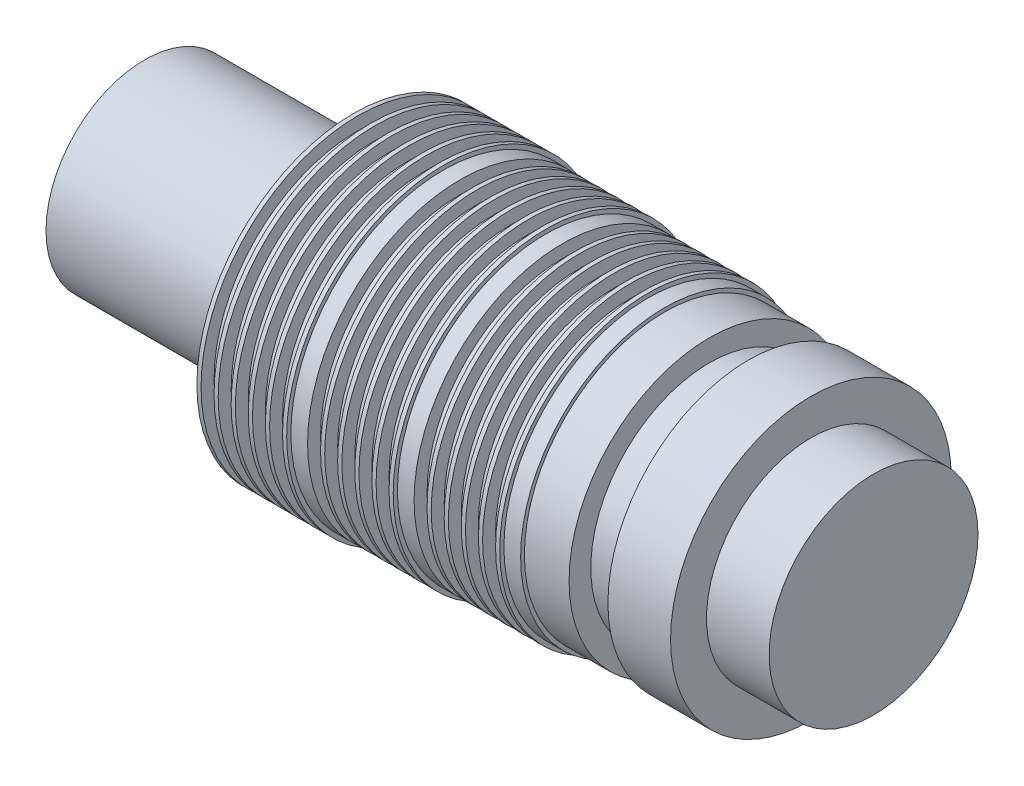
from build123d import *

# Parameters (mm, degrees)
SKETCH3_R           = 17.357767681
CUT_EXTRUDE1_DEPTH  = 114.5794
SKETCH4_R           = 6.35
BOSS_EXTRUDE1_DEPTH = 12.7
SKETCH5_R           = 8.5344
SKETCH5_R_2         = 6.35
BOSS_EXTRUDE2_DEPTH = 8.89
CUT_EXTRUDE2_START  = -3.81
SKETCH6_R           = 8.5344
SKETCH6_R_2         = 7.2136
CUT_EXTRUDE2_DEPTH  = 2.3622


with BuildPart() as part:
    # Sketch1 → Revolve1 (revolve)
    with BuildSketch(Plane.XY):
        Polygon((12.954, 9.525), (12.954, 8.7376), (13.7414, 8.7376), (13.7414, 9.525), (13.9954, 9.525), (13.9954, 8.7376), (14.7828, 8.7376), (14.7828, 9.525), (15.0368, 9.525), (15.0368, 8.7376), (15.8242, 8.7376), (15.8242, 9.525), (16.0782, 9.525), (16.0782, 8.7376), (16.8656, 8.7376), (16.8656, 9.525), (17.1196, 9.525), (17.1196, 8.7376), (17.907, 8.7376), (17.907, 9.525), (18.161, 9.525), (18.161, 9.271), (19.177, 9.271), (19.177, 8.4836), (19.9644, 8.4836), (19.9644, 9.271), (20.2184, 9.271), (20.2184, 8.4836), (21.0058, 8.4836), (21.0058, 9.271), (21.2598, 9.271), (21.2598, 8.4836), (22.0472, 8.4836), (22.0472, 9.271), (22.3012, 9.271), (22.3012, 8.4836), (23.0886, 8.4836), (23.0886, 9.271), (23.3426, 9.271), (23.3426, 8.4836), (24.13, 8.4836), (24.13, 9.271), (24.384, 9.271), (24.384, 9.017), (25.4, 9.017), (25.4, 8.2296), (26.1874, 8.2296), (26.1874, 9.017), (26.4414, 9.017), (26.4414, 8.2296), (27.2288, 8.2296), (27.2288, 9.017), (27.4828, 9.017), (27.4828, 8.2296), (28.2702, 8.2296), (28.2702, 9.017), (28.5242, 9.017), (28.5242, 8.2296), (29.3116, 8.2296), (29.3116, 9.017), (29.5656, 9.017), (29.5656, 8.2296), (30.353, 8.2296), (30.353, 9.017), (30.607, 9.017), (30.607, 8.763), (31.623, 8.763), (31.623, 7.9756), (32.4104, 7.9756), (32.4104, 8.763), (32.6644, 8.763), (32.6644, 7.9756), (33.4518, 7.9756), (33.4518, 8.763), (33.7058, 8.763), (33.7058, 7.9756), (34.4932, 7.9756), (34.4932, 8.763), (34.7472, 8.763), (34.7472, 7.9756), (35.5346, 7.9756), (35.5346, 8.763), (35.7886, 8.763), (35.7886, 7.9756), (36.576, 7.9756), (36.576, 8.763), (36.83, 8.763), (36.83, 8.509), (37.846, 8.509), (37.846, 7.7216), (38.6334, 7.7216), (38.6334, 8.509), (38.8874, 8.509), (38.8874, 7.7216), (39.6748, 7.7216), (39.6748, 8.509), (39.9288, 8.509), (39.9288, 7.7216), (40.7162, 7.7216), (40.7162, 8.509), (40.9702, 8.509), (40.9702, 7.7216), (41.7576, 7.7216), (41.7576, 8.509), (42.0116, 8.509), (42.0116, 7.7216), (42.799, 7.7216), (42.799, 8.509), (43.053, 8.509), (43.053, 8.255), (44.069, 8.255), (44.069, 7.4676), (44.8564, 7.4676), (44.8564, 8.255), (45.1104, 8.255), (45.1104, 7.4676), (45.8978, 7.4676), (45.8978, 8.255), (46.1518, 8.255), (46.1518, 7.4676), (46.9392, 7.4676), (46.9392, 8.255), (47.1932, 8.255), (47.1932, 7.4676), (47.9806, 7.4676), (47.9806, 8.255), (48.2346, 8.255), (48.2346, 7.4676), (49.022, 7.4676), (49.022, 8.255), (49.276, 8.255), (49.276, 5.999988), (74.676, 5.999988), (74.676, 0), (61.976, 0), (0, 0), (0, 5.999988), (12.7, 5.999988), (12.7, 9.525), align=None)
    revolve(axis=Axis((0, 0, 0), (1, 0, 0)))

    # Sketch3 → Cut-Extrude1 (cut)
    with BuildSketch(Plane(origin=(31.623, 0, 0), x_dir=(0, 0, -1), z_dir=(1, 0, 0))):
        Circle(SKETCH3_R)
    extrude(amount=CUT_EXTRUDE1_DEPTH, mode=Mode.SUBTRACT)

    # Sketch4 → Boss-Extrude1 (add)
    with BuildSketch(Plane(origin=(31.623, 0, 0), x_dir=(0, 0, -1), z_dir=(1, 0, 0))):
        Circle(SKETCH4_R)
    extrude(amount=BOSS_EXTRUDE1_DEPTH)

    # Sketch5 → Boss-Extrude2 (add)
    with BuildSketch(Plane(origin=(31.623, 0, 0), x_dir=(0, 0, -1), z_dir=(1, 0, 0))):
        Circle(SKETCH5_R)
        Circle(SKETCH5_R_2, mode=Mode.SUBTRACT)
    extrude(amount=BOSS_EXTRUDE2_DEPTH)

    # Sketch6 → Cut-Extrude2 (cut)
    with BuildSketch(Plane(origin=(40.513, 0, 0), x_dir=(0, 0, -1), z_dir=(1, 0, 0)).offset(CUT_EXTRUDE2_START)):
        Circle(SKETCH6_R)
        Circle(SKETCH6_R_2, mode=Mode.SUBTRACT)
    extrude(amount=-CUT_EXTRUDE2_DEPTH, mode=Mode.SUBTRACT)


solid = part.part
